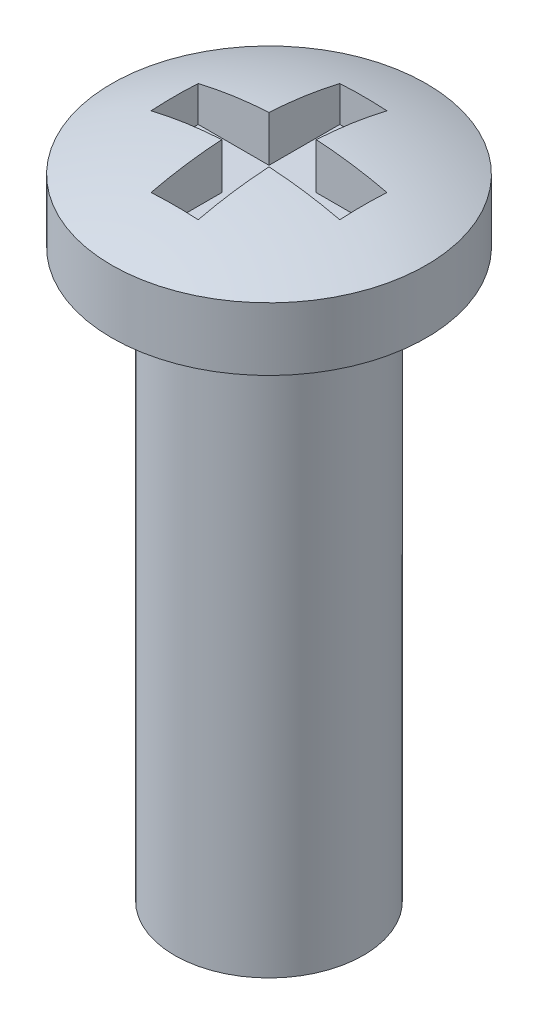
from build123d import *

# Parameters (mm, degrees)
SKETCH1_R           = 1.5
BOSS_EXTRUDE1_DEPTH = 9
SKETCH2_R           = 2.5
BOSS_EXTRUDE2_DEPTH = 1
DOME1_FACE_RADIUS   = 2.5
DOME1_HEIGHT        = 0.5
SKETCH3_W           = 1.125
SKETCH3_H           = 0.75
SKETCH3_W_2         = 0.75
SKETCH3_H_2         = 1.125
CUT_EXTRUDE1_DEPTH  = 0.75


with BuildPart() as part:
    # Sketch1 → Boss-Extrude1 (new body)
    with BuildSketch(Plane(origin=(0, 0, 0), x_dir=(1, 0, 0), z_dir=(0, 1, 0))):
        Circle(SKETCH1_R)
    extrude(amount=BOSS_EXTRUDE1_DEPTH)

    # Sketch2 → Boss-Extrude2 (add)
    with BuildSketch(Plane(origin=(0, 9, 0), x_dir=(1, 0, 0), z_dir=(0, 1, 0))):
        Circle(SKETCH2_R)
    extrude(amount=BOSS_EXTRUDE2_DEPTH)

    # Dome1: a dome of height H over a round flat face of radius A is a cap of a sphere of radius (A * A + H * H) / (2 * H)
    dome1_r = (DOME1_FACE_RADIUS * DOME1_FACE_RADIUS + DOME1_HEIGHT * DOME1_HEIGHT) / (2 * DOME1_HEIGHT)
    dome1_base = Plane((0, 10, 0), z_dir=(0, 1, 0))
    with Locations(dome1_base.offset(DOME1_HEIGHT - dome1_r)):
        dome1_ball = Sphere(dome1_r, mode=Mode.PRIVATE)
    add(split(dome1_ball, bisect_by=dome1_base, keep=Keep.TOP, mode=Mode.PRIVATE))

    # Sketch3 → Cut-Extrude1 (cut)
    with BuildSketch(Plane(origin=(0, 10.5, 0), x_dir=(1, 0, 0), z_dir=(0, 1, 0))):
        with Locations((-0.9375, 0)):
            Rectangle(SKETCH3_W, SKETCH3_H)
        Rectangle(SKETCH3_W_2, SKETCH3_H)
        with Locations((0, 0.9375)):
            Rectangle(SKETCH3_W_2, SKETCH3_H_2)
        with Locations((0.9375, 0)):
            Rectangle(SKETCH3_W, SKETCH3_H)
        with Locations((0, -0.9375)):
            Rectangle(SKETCH3_W_2, SKETCH3_H_2)
    extrude(amount=-CUT_EXTRUDE1_DEPTH, mode=Mode.SUBTRACT)


solid = part.part
